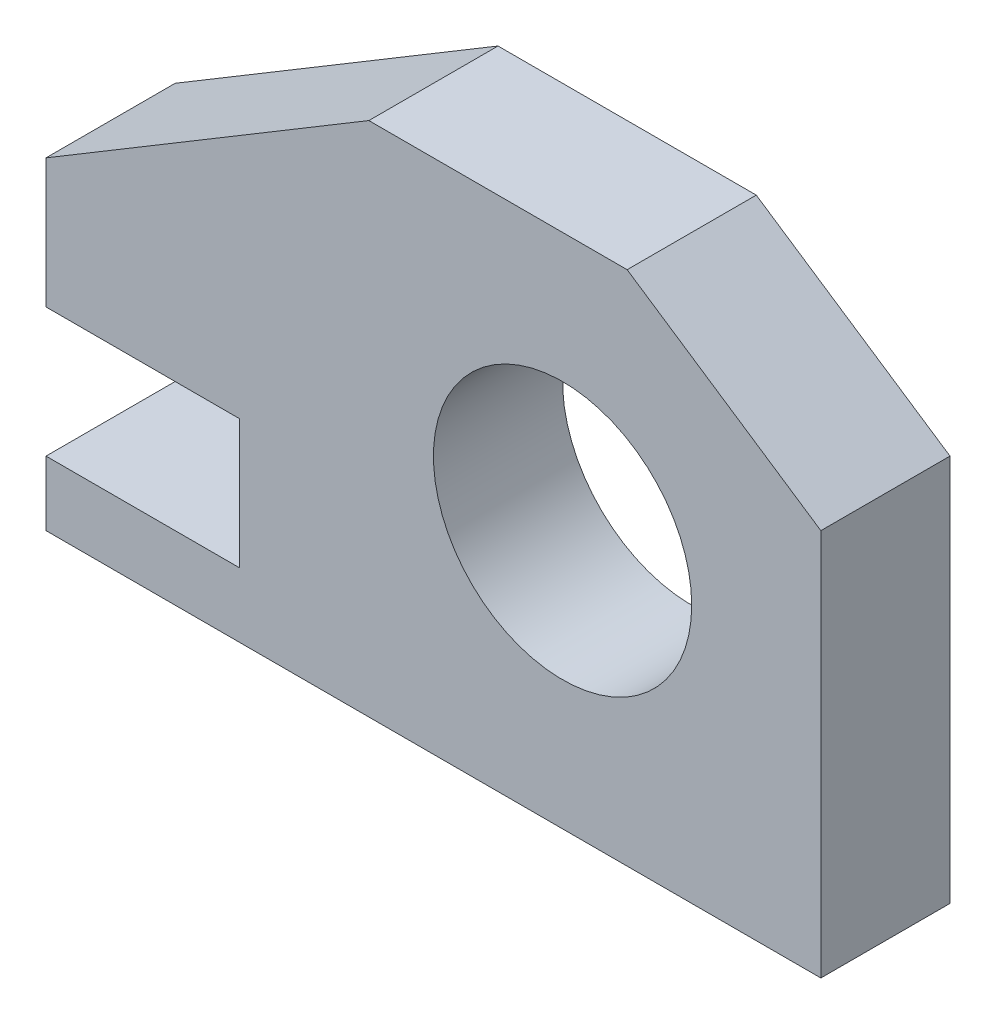
from build123d import *

# Parameters (mm, degrees)
SKETCH1_R           = 12.7
BOSS_EXTRUDE1_DEPTH = 12.7


with BuildPart() as part:
    # Sketch1 → Boss-Extrude1 (new body)
    with BuildSketch(Plane.XY):
        Polygon((0, 0), (0, 38.1), (-19.05, 50.8), (-44.45, 50.8), (-76.2, 31.75), (-76.2, 19.05), (-57.15, 19.05), (-57.15, 6.35), (-76.2, 6.35), (-76.2, 0), align=None)
        with Locations((-25.4, 25.4)):
            Circle(SKETCH1_R, mode=Mode.SUBTRACT)
    extrude(amount=BOSS_EXTRUDE1_DEPTH)


solid = part.part
